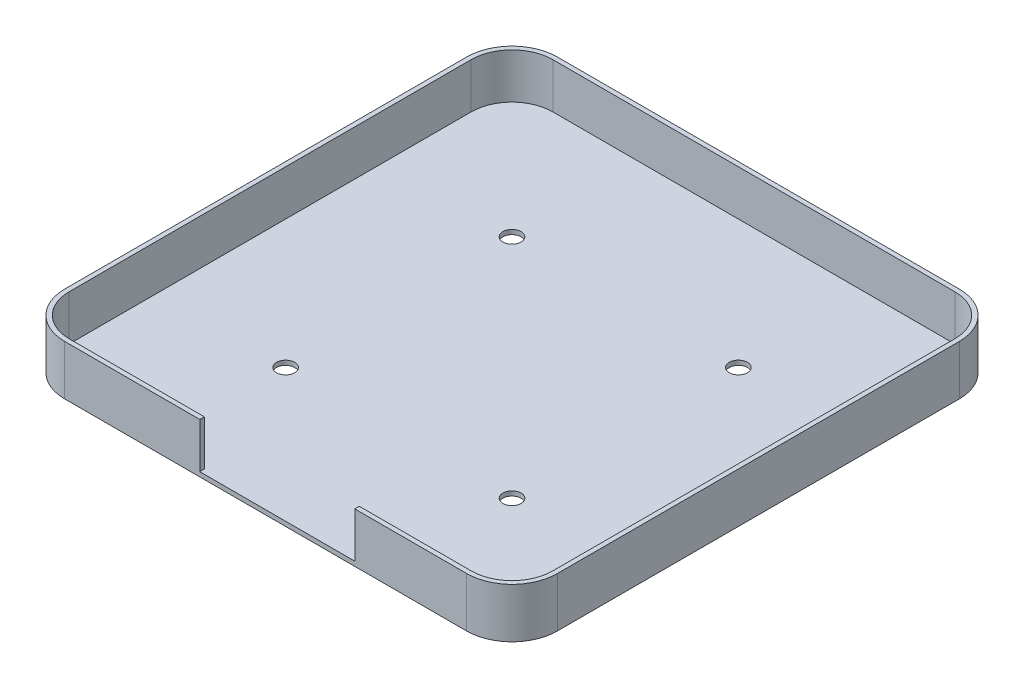
from build123d import *

# Parameters (mm, degrees)
SKETCH1_R           = 2
BOSS_EXTRUDE1_DEPTH = 1
BOSS_EXTRUDE2_DEPTH = 11
SKETCH3_W           = 34.23
SKETCH3_H           = 19.064187878
CUT_EXTRUDE2_DEPTH  = 1


with BuildPart() as part:
    # Sketch1 → Boss-Extrude1 (new body)
    with BuildSketch(Plane(origin=(0, 0, 0), x_dir=(1, 0, 0), z_dir=(0, 1, 0))):
        with BuildLine():
            ThreePointArc((-44.4, -53.4), (-50.763961031, -50.763961031), (-53.4, -44.4))
            Line((-53.4, -44.4), (-53.4, 44.4))
            ThreePointArc((-53.4, 44.4), (-50.763961031, 50.763961031), (-44.4, 53.4))
            Line((-44.4, 53.4), (44.4, 53.4))
            ThreePointArc((44.4, 53.4), (50.763961031, 50.763961031), (53.4, 44.4))
            Line((53.4, 44.4), (53.4, -44.4))
            ThreePointArc((53.4, -44.4), (50.763961031, -50.763961031), (44.4, -53.4))
            Line((44.4, -53.4), (-44.4, -53.4))
        make_face()
        with BuildLine():
            Line((-29, -25), (-29, 25))
            ThreePointArc((-29, 25), (-27.828427125, 27.828427125), (-25, 29))
            Line((-25, 29), (25, 29))
            ThreePointArc((25, 29), (27.828427125, 27.828427125), (29, 25))
            Line((29, 25), (29, -25))
            ThreePointArc((29, -25), (27.828427125, -27.828427125), (25, -29))
            Line((25, -29), (-25, -29))
            ThreePointArc((-25, -29), (-27.828427125, -27.828427125), (-29, -25))
        make_face(mode=Mode.SUBTRACT)
        with BuildLine():
            ThreePointArc((-29, 25), (-27.828427125, 27.828427125), (-25, 29))
            Line((-25, 29), (25, 29))
            ThreePointArc((25, 29), (27.828427125, 27.828427125), (29, 25))
            Line((29, 25), (29, -25))
            ThreePointArc((29, -25), (27.828427125, -27.828427125), (25, -29))
            Line((25, -29), (-25, -29))
            ThreePointArc((-25, -29), (-27.828427125, -27.828427125), (-29, -25))
            Line((-29, -25), (-29, 25))
        make_face()
        with Locations((25, -25)):
            Circle(SKETCH1_R, mode=Mode.SUBTRACT)
        with Locations((25, 25)):
            Circle(SKETCH1_R, mode=Mode.SUBTRACT)
        with Locations((-25, 25)):
            Circle(SKETCH1_R, mode=Mode.SUBTRACT)
        with Locations((-25, -25)):
            Circle(SKETCH1_R, mode=Mode.SUBTRACT)
    extrude(amount=BOSS_EXTRUDE1_DEPTH)

    # Sketch1_5 → Boss-Extrude2 (add)
    with BuildSketch(Plane(origin=(0, 0, 0), x_dir=(1, 0, 0), z_dir=(0, 1, 0))):
        with BuildLine():
            ThreePointArc((-54.4, 44.4), (-51.471067812, 51.471067812), (-44.4, 54.4))
            Line((-44.4, 54.4), (44.4, 54.4))
            ThreePointArc((44.4, 54.4), (51.471067812, 51.471067812), (54.4, 44.4))
            Line((54.4, 44.4), (54.4, -44.4))
            ThreePointArc((54.4, -44.4), (51.471067812, -51.471067812), (44.4, -54.4))
            Line((44.4, -54.4), (-44.4, -54.4))
            ThreePointArc((-44.4, -54.4), (-51.471067812, -51.471067812), (-54.4, -44.4))
            Line((-54.4, -44.4), (-54.4, 44.4))
        make_face()
        with BuildLine():
            Line((-44.4, -53.4), (44.4, -53.4))
            ThreePointArc((44.4, -53.4), (50.763961031, -50.763961031), (53.4, -44.4))
            Line((53.4, -44.4), (53.4, 44.4))
            ThreePointArc((53.4, 44.4), (50.763961031, 50.763961031), (44.4, 53.4))
            Line((44.4, 53.4), (-44.4, 53.4))
            ThreePointArc((-44.4, 53.4), (-50.763961031, 50.763961031), (-53.4, 44.4))
            Line((-53.4, 44.4), (-53.4, -44.4))
            ThreePointArc((-53.4, -44.4), (-50.763961031, -50.763961031), (-44.4, -53.4))
        make_face(mode=Mode.SUBTRACT)
    extrude(amount=BOSS_EXTRUDE2_DEPTH)

    # Sketch3 → Cut-Extrude2 (cut)
    with BuildSketch(Plane(origin=(0, 0, 54.4), x_dir=(-1, 0, 0), z_dir=(0, 0, -1))):
        with Locations((-2.557601794, 10.532093939)):
            Rectangle(SKETCH3_W, SKETCH3_H)
    extrude(amount=CUT_EXTRUDE2_DEPTH, mode=Mode.SUBTRACT)


solid = part.part
